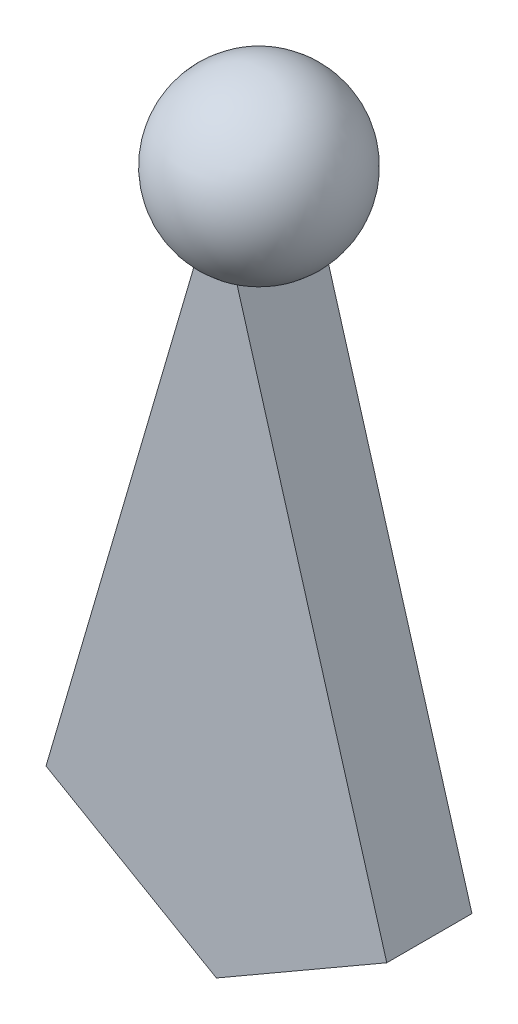
from build123d import *

# Parameters (mm, degrees)
AUFSATZ_LINEAR_AUSTRAGEN1_DEPTH = 2.5


with BuildPart() as part:
    # Skizze1 → Rotation1 (revolve)
    with BuildSketch(Plane.XY):
        with BuildLine():
            Line((0, 45), (0, 35))
            ThreePointArc((0, 35), (5, 40), (0, 45))
        make_face()
    revolve(axis=Axis((0, 0, 0), (0, 1, 0)))

    # Skizze2 → Aufsatz-Linear austragen1 (add, symmetric)
    with BuildSketch(Plane.XY):
        Polygon((0, 40), (-10, 5.773502692), (0, 0), (10, 5.773502692), align=None)
    extrude(amount=AUFSATZ_LINEAR_AUSTRAGEN1_DEPTH, both=True)


solid = part.part
